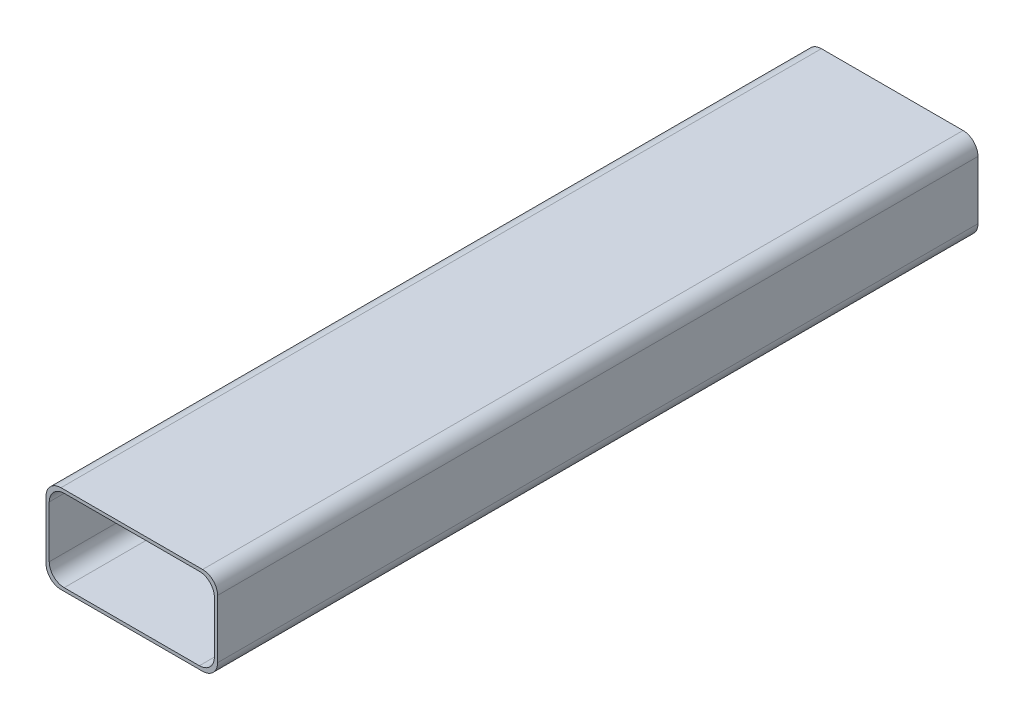
from build123d import *

# Parameters (mm, degrees)
BOSS_EXTRUDE1_DEPTH = 508


with BuildPart() as part:
    # Sketch1 → Boss-Extrude1 (new body)
    with BuildSketch(Plane.XY):
        with BuildLine():
            Line((-47.3151, -29.464), (47.3151, -29.464))
            ThreePointArc((47.3151, -29.464), (54.386167812, -26.535067812), (57.3151, -19.464))
            Line((57.3151, -19.464), (57.3151, 19.464))
            ThreePointArc((57.3151, 19.464), (54.386167812, 26.535067812), (47.3151, 29.464))
            Line((47.3151, 29.464), (-47.3151, 29.464))
            ThreePointArc((-47.3151, 29.464), (-54.386167812, 26.535067812), (-57.3151, 19.464))
            Line((-57.3151, 19.464), (-57.3151, -19.464))
            ThreePointArc((-57.3151, -19.464), (-54.386167812, -26.535067812), (-47.3151, -29.464))
        make_face()
        with BuildLine():
            Line((-45.1561, -27.305), (45.1561, -27.305))
            ThreePointArc((45.1561, -27.305), (52.227167812, -24.376067812), (55.1561, -17.305))
            Line((55.1561, -17.305), (55.1561, 17.305))
            ThreePointArc((55.1561, 17.305), (52.227167812, 24.376067812), (45.1561, 27.305))
            Line((45.1561, 27.305), (-45.1561, 27.305))
            ThreePointArc((-45.1561, 27.305), (-52.227167812, 24.376067812), (-55.1561, 17.305))
            Line((-55.1561, 17.305), (-55.1561, -17.305))
            ThreePointArc((-55.1561, -17.305), (-52.227167812, -24.376067812), (-45.1561, -27.305))
        make_face(mode=Mode.SUBTRACT)
    extrude(amount=BOSS_EXTRUDE1_DEPTH)


solid = part.part
